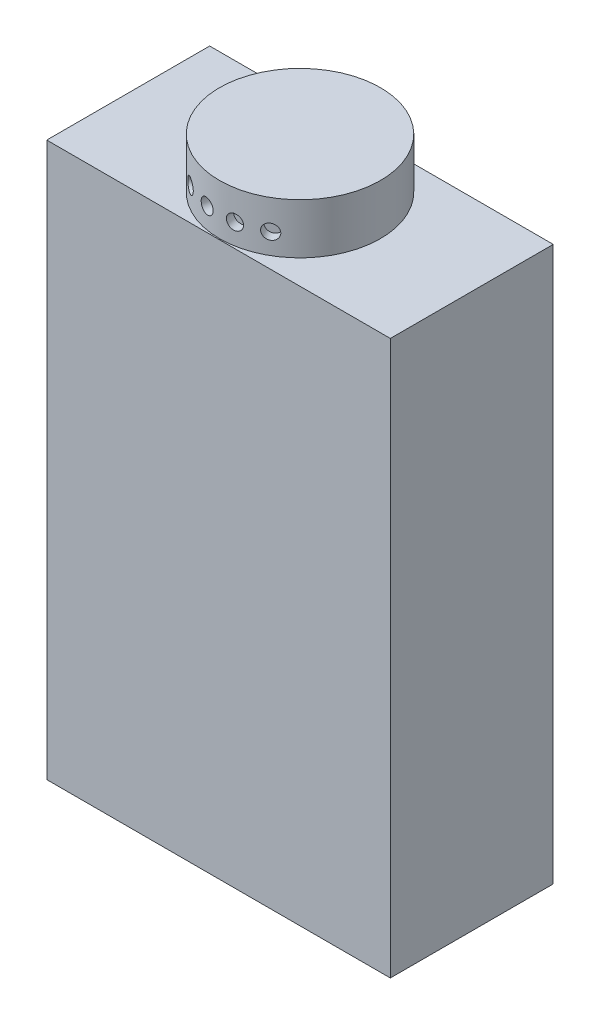
from build123d import *

# Parameters (mm, degrees)
SKETCH1_W           = 116
SKETCH1_H           = 55
BOSS_EXTRUDE1_DEPTH = 187
SKETCH2_R           = 27.163974649
BOSS_EXTRUDE2_DEPTH = 17
CIRPATTERN1_COUNT   = 4
CIRPATTERN1_ANGLE   = 60


with BuildPart() as part:
    # Sketch1 → Boss-Extrude1 (new body)
    with BuildSketch(Plane(origin=(0, 0, 0), x_dir=(1, 0, 0), z_dir=(0, 1, 0))):
        Rectangle(SKETCH1_W, SKETCH1_H)
    extrude(amount=BOSS_EXTRUDE1_DEPTH)

    # Sketch2 → Boss-Extrude2 (add)
    with BuildSketch(Plane(origin=(0, 187, 0), x_dir=(1, 0, 0), z_dir=(0, 1, 0))):
        Circle(SKETCH2_R)
    extrude(amount=BOSS_EXTRUDE2_DEPTH)

    # Sketch4 → Cut-Revolve1 (revolve, cut)
    with BuildSketch(Plane(origin=(0, 194, 0), x_dir=(-1, 0, 0), z_dir=(0, 1, 0))):
        Polygon((-14.582777308, 25.258111213), (-12.417713798, 26.508111213), (-9.861835709, 22.081200504), (-12.026899219, 20.831200504), align=None)
    cut_revolve1 = revolve(axis=Axis((0, 194, 0), (0.5, 0, 0.866025404)), mode=Mode.SUBTRACT)

    # CirPattern1: Cut-Revolve1 ×4 about axis
    cirpattern1_axis = Axis((0, 0, 0), (0, -1, 0))
    for i in range(1, CIRPATTERN1_COUNT):
        add(cut_revolve1.rotate(cirpattern1_axis, i * CIRPATTERN1_ANGLE / (CIRPATTERN1_COUNT - 1)), mode=Mode.SUBTRACT)


solid = part.part
